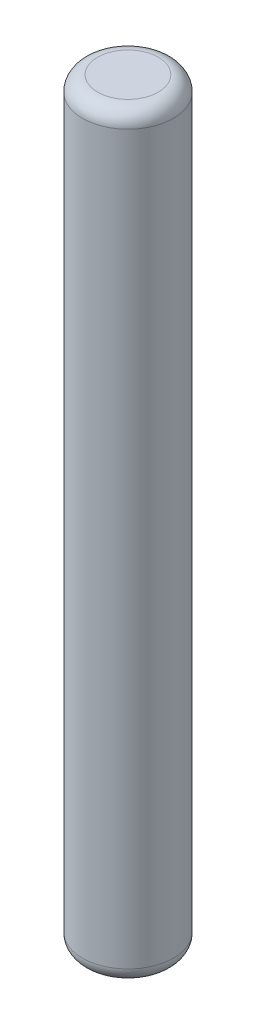
from build123d import *

# Parameters (mm, degrees)
SKETCH1_R           = 1.5
BOSS_EXTRUDE1_DEPTH = 25
FILLET1_R           = 0.5


with BuildPart() as part:
    # Sketch1 → Boss-Extrude1 (new body)
    with BuildSketch(Plane(origin=(0, 0, 0), x_dir=(1, 0, 0), z_dir=(0, 1, 0))):
        Circle(SKETCH1_R)
    extrude(amount=BOSS_EXTRUDE1_DEPTH)

    # Fillet1
    fillet1_edges = [part.edges().sort_by_distance(p)[0] for p in [
        (-1.5, 0, 0),
        (-1.5, 25, 0),
    ]]
    fillet(fillet1_edges, radius=FILLET1_R)


solid = part.part
